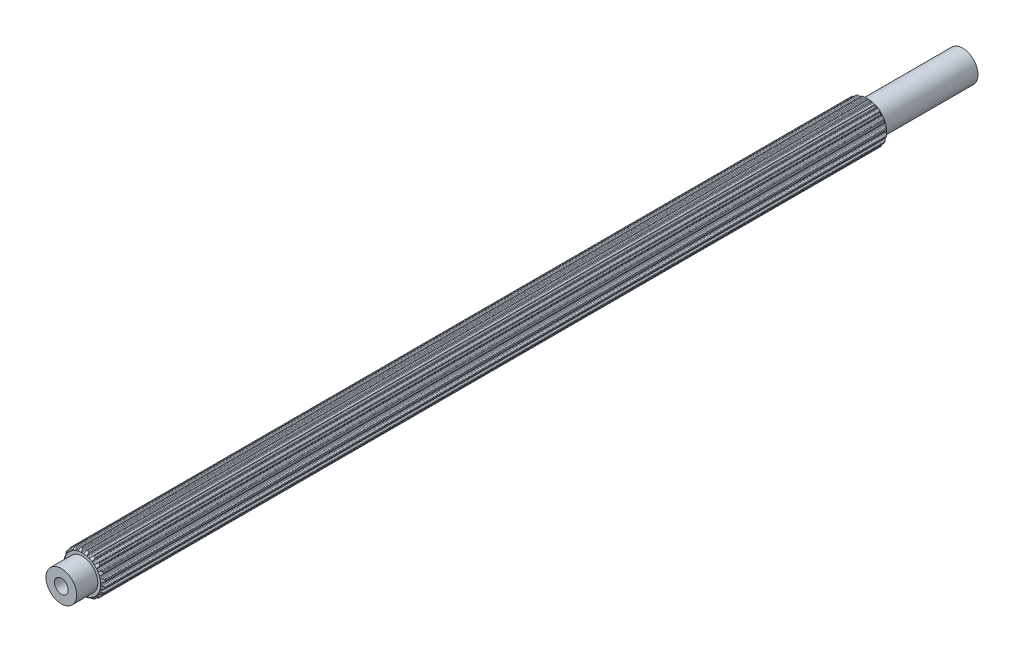
from build123d import *

# Parameters (mm, degrees)
BOSS_EXTRUDE1_DEPTH            = 70.0786
BOSS_EXTRUDE1_DEPTH_BACK       = 58.1406
SKETCH2_R                      = 2.5019
BOSS_EXTRUDE2_DEPTH            = 73.533
CUT_EXTRUDE1_REACH             = 75.533
SKETCH6_R                      = 1.1303
CUT_EXTRUDE1_DIRECTION_2_REACH = 75.533
SKETCH7_R                      = 1.1303
BOSS_EXTRUDE3_DEPTH            = 64.008
BOSS_EXTRUDE3_DEPTH_BACK       = 64.008


with BuildPart() as part:
    # Sketch1 → Boss-Extrude1 (new body, two sides)
    with BuildSketch(Plane.XY) as boss_extrude1_sk:
        with BuildLine():
            Line((-0.106949245, 2.969874934), (0.106949245, 2.969874934))
            ThreePointArc((0.106949245, 2.969874934), (0.196343213, 2.986924176), (0.253739238, 3.057547504))
            Line((0.253739238, 3.057547504), (0.315888147, 3.237526941))
            ThreePointArc((0.315888147, 3.237526941), (0.359032156, 3.298322911), (0.4281449, 3.326269005))
            Line((0.4281449, 3.326269005), (0.620027588, 3.2937547))
            ThreePointArc((0.620027588, 3.2937547), (0.689621142, 3.24802576), (0.718272212, 3.169836791))
            Line((0.718272212, 3.169836791), (0.724389167, 2.979527391))
            ThreePointArc((0.724389167, 2.979527391), (0.750934762, 2.9040661), (0.816027049, 2.857568043))
            Line((0.816027049, 2.857568043), (1.019456602, 2.791469774))
            ThreePointArc((1.019456602, 2.791469774), (1.109743823, 2.780060312), (1.186154496, 2.829490741))
            Line((1.186154496, 2.829490741), (1.300878326, 2.981456288))
            ThreePointArc((1.300878326, 2.981456288), (1.360697704, 3.02594446), (1.435063648, 3.031165762))
            Line((1.435063648, 3.031165762), (1.607507455, 2.940947809))
            ThreePointArc((1.607507455, 2.940947809), (1.659563839, 2.875951412), (1.662650905, 2.792735615))
            Line((1.662650905, 2.792735615), (1.609659636, 2.609850378))
            ThreePointArc((1.609659636, 2.609850378), (1.611587176, 2.529879385), (1.659124931, 2.465542482))
            Line((1.659124931, 2.465542482), (1.832172444, 2.339816104))
            ThreePointArc((1.832172444, 2.339816104), (1.914514976, 2.301064775), (2.002460687, 2.32446371))
            Line((2.002460687, 2.32446371), (2.158529469, 2.433539921))
            ThreePointArc((2.158529469, 2.433539921), (2.229168681, 2.457365482), (2.301508367, 2.439350895))
            Line((2.301508367, 2.439350895), (2.437633293, 2.300260456))
            ThreePointArc((2.437633293, 2.300260456), (2.467056864, 2.222358901), (2.444277744, 2.14226202))
            Line((2.444277744, 2.14226202), (2.337365406, 1.984703026))
            ThreePointArc((2.337365406, 1.984703026), (2.314486209, 1.908050449), (2.339816104, 1.832172444))
            Line((2.339816104, 1.832172444), (2.465542482, 1.659124931))
            ThreePointArc((2.465542482, 1.659124931), (2.531880064, 1.596824985), (2.622752074, 1.591901975))
            Line((2.622752074, 1.591901975), (2.804888709, 1.64741171))
            ThreePointArc((2.804888709, 1.64741171), (2.879433095, 1.648242449), (2.942665411, 1.608755366))
            Line((2.942665411, 1.608755366), (3.0291466, 1.434407582))
            ThreePointArc((3.0291466, 1.434407582), (3.033057175, 1.351226417), (2.986641646, 1.282088892))
            Line((2.986641646, 1.282088892), (2.836273564, 1.165279113))
            ThreePointArc((2.836273564, 1.165279113), (2.790827206, 1.099448241), (2.791469774, 1.019456602))
            Line((2.791469774, 1.019456602), (2.857568043, 0.816027049))
            ThreePointArc((2.857568043, 0.816027049), (2.901407091, 0.736276839), (2.986310214, 0.703513784))
            Line((2.986310214, 0.703513784), (3.1766859, 0.700023363))
            ThreePointArc((3.1766859, 0.700023363), (3.247838536, 0.677777961), (3.295773863, 0.620683653))
            Line((3.295773863, 0.620683653), (3.324145932, 0.4281449))
            ThreePointArc((3.324145932, 0.4281449), (3.302160717, 0.347826477), (3.236652255, 0.29641597))
            Line((3.236652255, 0.29641597), (3.057547504, 0.231789562))
            ThreePointArc((3.057547504, 0.231789562), (2.993982591, 0.183224379), (2.969874934, 0.106949245))
            Line((2.969874934, 0.106949245), (2.969874934, -0.106949245))
            ThreePointArc((2.969874934, -0.106949245), (2.986924176, -0.196343213), (3.057547504, -0.253739238))
            Line((3.057547504, -0.253739238), (3.237526941, -0.315888147))
            ThreePointArc((3.237526941, -0.315888147), (3.298322911, -0.359032156), (3.326269005, -0.4281449))
            Line((3.326269005, -0.4281449), (3.2937547, -0.620027588))
            ThreePointArc((3.2937547, -0.620027588), (3.24802576, -0.689621142), (3.169836791, -0.718272212))
            Line((3.169836791, -0.718272212), (2.979527391, -0.724389167))
            ThreePointArc((2.979527391, -0.724389167), (2.9040661, -0.750934762), (2.857568043, -0.816027049))
            Line((2.857568043, -0.816027049), (2.791469774, -1.019456602))
            ThreePointArc((2.791469774, -1.019456602), (2.780060312, -1.109743823), (2.829490741, -1.186154496))
            Line((2.829490741, -1.186154496), (2.981456288, -1.300878326))
            ThreePointArc((2.981456288, -1.300878326), (3.02594446, -1.360697704), (3.031165762, -1.435063648))
            Line((3.031165762, -1.435063648), (2.940947809, -1.607507455))
            ThreePointArc((2.940947809, -1.607507455), (2.875951412, -1.659563839), (2.792735615, -1.662650905))
            Line((2.792735615, -1.662650905), (2.609850378, -1.609659636))
            ThreePointArc((2.609850378, -1.609659636), (2.529879385, -1.611587176), (2.465542482, -1.659124931))
            Line((2.465542482, -1.659124931), (2.339816104, -1.832172444))
            ThreePointArc((2.339816104, -1.832172444), (2.301064775, -1.914514976), (2.32446371, -2.002460687))
            Line((2.32446371, -2.002460687), (2.433539921, -2.158529469))
            ThreePointArc((2.433539921, -2.158529469), (2.457365482, -2.229168681), (2.439350895, -2.301508367))
            Line((2.439350895, -2.301508367), (2.300260456, -2.437633293))
            ThreePointArc((2.300260456, -2.437633293), (2.222358901, -2.467056864), (2.14226202, -2.444277744))
            Line((2.14226202, -2.444277744), (1.984703026, -2.337365406))
            ThreePointArc((1.984703026, -2.337365406), (1.908050449, -2.314486209), (1.832172444, -2.339816104))
            Line((1.832172444, -2.339816104), (1.659124931, -2.465542482))
            ThreePointArc((1.659124931, -2.465542482), (1.596824985, -2.531880064), (1.591901975, -2.622752074))
            Line((1.591901975, -2.622752074), (1.64741171, -2.804888709))
            ThreePointArc((1.64741171, -2.804888709), (1.648242449, -2.879433095), (1.608755366, -2.942665411))
            Line((1.608755366, -2.942665411), (1.434407582, -3.0291466))
            ThreePointArc((1.434407582, -3.0291466), (1.351226417, -3.033057175), (1.282088892, -2.986641646))
            Line((1.282088892, -2.986641646), (1.165279113, -2.836273564))
            ThreePointArc((1.165279113, -2.836273564), (1.099448241, -2.790827206), (1.019456602, -2.791469774))
            Line((1.019456602, -2.791469774), (0.816027049, -2.857568043))
            ThreePointArc((0.816027049, -2.857568043), (0.736276839, -2.901407091), (0.703513784, -2.986310214))
            Line((0.703513784, -2.986310214), (0.700023363, -3.1766859))
            ThreePointArc((0.700023363, -3.1766859), (0.677777961, -3.247838536), (0.620683653, -3.295773863))
            Line((0.620683653, -3.295773863), (0.4281449, -3.324145932))
            ThreePointArc((0.4281449, -3.324145932), (0.347826477, -3.302160717), (0.29641597, -3.236652255))
            Line((0.29641597, -3.236652255), (0.231789562, -3.057547504))
            ThreePointArc((0.231789562, -3.057547504), (0.183224379, -2.993982591), (0.106949245, -2.969874934))
            Line((0.106949245, -2.969874934), (-0.106949245, -2.969874934))
            ThreePointArc((-0.106949245, -2.969874934), (-0.196343213, -2.986924176), (-0.253739238, -3.057547504))
            Line((-0.253739238, -3.057547504), (-0.315888147, -3.237526941))
            ThreePointArc((-0.315888147, -3.237526941), (-0.359032156, -3.298322911), (-0.4281449, -3.326269005))
            Line((-0.4281449, -3.326269005), (-0.620027588, -3.2937547))
            ThreePointArc((-0.620027588, -3.2937547), (-0.689621142, -3.24802576), (-0.718272212, -3.169836791))
            Line((-0.718272212, -3.169836791), (-0.724389167, -2.979527391))
            ThreePointArc((-0.724389167, -2.979527391), (-0.750934762, -2.9040661), (-0.816027049, -2.857568043))
            Line((-0.816027049, -2.857568043), (-1.019456602, -2.791469774))
            ThreePointArc((-1.019456602, -2.791469774), (-1.109743823, -2.780060312), (-1.186154496, -2.829490741))
            Line((-1.186154496, -2.829490741), (-1.300878326, -2.981456288))
            ThreePointArc((-1.300878326, -2.981456288), (-1.360697704, -3.02594446), (-1.435063648, -3.031165762))
            Line((-1.435063648, -3.031165762), (-1.607507455, -2.940947809))
            ThreePointArc((-1.607507455, -2.940947809), (-1.659563839, -2.875951412), (-1.662650905, -2.792735615))
            Line((-1.662650905, -2.792735615), (-1.609659636, -2.609850378))
            ThreePointArc((-1.609659636, -2.609850378), (-1.611587176, -2.529879385), (-1.659124931, -2.465542482))
            Line((-1.659124931, -2.465542482), (-1.832172444, -2.339816104))
            ThreePointArc((-1.832172444, -2.339816104), (-1.914514976, -2.301064775), (-2.002460687, -2.32446371))
            Line((-2.002460687, -2.32446371), (-2.158529469, -2.433539921))
            ThreePointArc((-2.158529469, -2.433539921), (-2.229168681, -2.457365482), (-2.301508367, -2.439350895))
            Line((-2.301508367, -2.439350895), (-2.437633293, -2.300260456))
            ThreePointArc((-2.437633293, -2.300260456), (-2.467056864, -2.222358901), (-2.444277744, -2.14226202))
            Line((-2.444277744, -2.14226202), (-2.337365406, -1.984703026))
            ThreePointArc((-2.337365406, -1.984703026), (-2.314486209, -1.908050449), (-2.339816104, -1.832172444))
            Line((-2.339816104, -1.832172444), (-2.465542482, -1.659124931))
            ThreePointArc((-2.465542482, -1.659124931), (-2.531880064, -1.596824985), (-2.622752074, -1.591901975))
            Line((-2.622752074, -1.591901975), (-2.804888709, -1.64741171))
            ThreePointArc((-2.804888709, -1.64741171), (-2.879433095, -1.648242449), (-2.942665411, -1.608755366))
            Line((-2.942665411, -1.608755366), (-3.0291466, -1.434407582))
            ThreePointArc((-3.0291466, -1.434407582), (-3.033057175, -1.351226417), (-2.986641646, -1.282088892))
            Line((-2.986641646, -1.282088892), (-2.836273564, -1.165279113))
            ThreePointArc((-2.836273564, -1.165279113), (-2.790827206, -1.099448241), (-2.791469774, -1.019456602))
            Line((-2.791469774, -1.019456602), (-2.857568043, -0.816027049))
            ThreePointArc((-2.857568043, -0.816027049), (-2.901407091, -0.736276839), (-2.986310214, -0.703513784))
            Line((-2.986310214, -0.703513784), (-3.1766859, -0.700023363))
            ThreePointArc((-3.1766859, -0.700023363), (-3.247838536, -0.677777961), (-3.295773863, -0.620683653))
            Line((-3.295773863, -0.620683653), (-3.324145932, -0.4281449))
            ThreePointArc((-3.324145932, -0.4281449), (-3.302160717, -0.347826477), (-3.236652255, -0.29641597))
            Line((-3.236652255, -0.29641597), (-3.057547504, -0.231789562))
            ThreePointArc((-3.057547504, -0.231789562), (-2.993982591, -0.183224379), (-2.969874934, -0.106949245))
            Line((-2.969874934, -0.106949245), (-2.969874934, 0.106949245))
            ThreePointArc((-2.969874934, 0.106949245), (-2.986924176, 0.196343213), (-3.057547504, 0.253739238))
            Line((-3.057547504, 0.253739238), (-3.237526941, 0.315888147))
            ThreePointArc((-3.237526941, 0.315888147), (-3.298322911, 0.359032156), (-3.326269005, 0.4281449))
            Line((-3.326269005, 0.4281449), (-3.2937547, 0.620027588))
            ThreePointArc((-3.2937547, 0.620027588), (-3.24802576, 0.689621142), (-3.169836791, 0.718272212))
            Line((-3.169836791, 0.718272212), (-2.979527391, 0.724389167))
            ThreePointArc((-2.979527391, 0.724389167), (-2.9040661, 0.750934762), (-2.857568043, 0.816027049))
            Line((-2.857568043, 0.816027049), (-2.791469774, 1.019456602))
            ThreePointArc((-2.791469774, 1.019456602), (-2.780060312, 1.109743823), (-2.829490741, 1.186154496))
            Line((-2.829490741, 1.186154496), (-2.981456288, 1.300878326))
            ThreePointArc((-2.981456288, 1.300878326), (-3.02594446, 1.360697704), (-3.031165762, 1.435063648))
            Line((-3.031165762, 1.435063648), (-2.940947809, 1.607507455))
            ThreePointArc((-2.940947809, 1.607507455), (-2.875951412, 1.659563839), (-2.792735615, 1.662650905))
            Line((-2.792735615, 1.662650905), (-2.609850378, 1.609659636))
            ThreePointArc((-2.609850378, 1.609659636), (-2.529879385, 1.611587176), (-2.465542482, 1.659124931))
            Line((-2.465542482, 1.659124931), (-2.339816104, 1.832172444))
            ThreePointArc((-2.339816104, 1.832172444), (-2.301064775, 1.914514976), (-2.32446371, 2.002460687))
            Line((-2.32446371, 2.002460687), (-2.433539921, 2.158529469))
            ThreePointArc((-2.433539921, 2.158529469), (-2.457365482, 2.229168681), (-2.439350895, 2.301508367))
            Line((-2.439350895, 2.301508367), (-2.300260456, 2.437633293))
            ThreePointArc((-2.300260456, 2.437633293), (-2.222358901, 2.467056864), (-2.14226202, 2.444277744))
            Line((-2.14226202, 2.444277744), (-1.984703026, 2.337365406))
            ThreePointArc((-1.984703026, 2.337365406), (-1.908050449, 2.314486209), (-1.832172444, 2.339816104))
            Line((-1.832172444, 2.339816104), (-1.659124931, 2.465542482))
            ThreePointArc((-1.659124931, 2.465542482), (-1.596824985, 2.531880064), (-1.591901975, 2.622752074))
            Line((-1.591901975, 2.622752074), (-1.64741171, 2.804888709))
            ThreePointArc((-1.64741171, 2.804888709), (-1.648242449, 2.879433095), (-1.608755366, 2.942665411))
            Line((-1.608755366, 2.942665411), (-1.434407582, 3.0291466))
            ThreePointArc((-1.434407582, 3.0291466), (-1.351226417, 3.033057175), (-1.282088892, 2.986641646))
            Line((-1.282088892, 2.986641646), (-1.165279113, 2.836273564))
            ThreePointArc((-1.165279113, 2.836273564), (-1.099448241, 2.790827206), (-1.019456602, 2.791469774))
            Line((-1.019456602, 2.791469774), (-0.816027049, 2.857568043))
            ThreePointArc((-0.816027049, 2.857568043), (-0.736276839, 2.901407091), (-0.703513784, 2.986310214))
            Line((-0.703513784, 2.986310214), (-0.700023363, 3.1766859))
            ThreePointArc((-0.700023363, 3.1766859), (-0.677777961, 3.247838536), (-0.620683653, 3.295773863))
            Line((-0.620683653, 3.295773863), (-0.4281449, 3.324145932))
            ThreePointArc((-0.4281449, 3.324145932), (-0.347826477, 3.302160717), (-0.29641597, 3.236652255))
            Line((-0.29641597, 3.236652255), (-0.231789562, 3.057547504))
            ThreePointArc((-0.231789562, 3.057547504), (-0.183224379, 2.993982591), (-0.106949245, 2.969874934))
        make_face()
    extrude(amount=BOSS_EXTRUDE1_DEPTH)
    extrude(boss_extrude1_sk.sketch, amount=-BOSS_EXTRUDE1_DEPTH_BACK)

    # Sketch2 → Boss-Extrude2 (add, symmetric)
    with BuildSketch(Plane.XY):
        Circle(SKETCH2_R)
    extrude(amount=BOSS_EXTRUDE2_DEPTH, both=True)

    # Sketch3 → Cut-Revolve1 (revolve, cut)
    with BuildSketch(Plane(origin=(0, 0, 0), x_dir=(0, 0, -1), z_dir=(1, 0, 0))):
        Polygon((-68.947375505, 4.101099429), (-70.0786, 2.969874934), (-70.0786, 4.101099429), align=None)
        Polygon((58.1406, 54.854469155), (58.1406, 2.969874934), (32.198302889, 28.912172045), align=None)
    revolve(axis=Axis((0, 0, 14.360793934), (0, 0, -1)), mode=Mode.SUBTRACT)

    # Cut-Extrude1: up to this face of the body (flat: up to its plane)
    cut_extrude1_end = Plane(part.part.faces().sort_by_distance((0, 0, 73.533))[0])
    # Sketch6 → Cut-Extrude1 (cut, up to the picked face)
    with BuildSketch(Plane.XY, mode=Mode.PRIVATE) as cut_extrude1_sk1:
        Circle(SKETCH6_R)
    cut_extrude1_tool1 = split(extrude(cut_extrude1_sk1.sketch, amount=CUT_EXTRUDE1_REACH, mode=Mode.PRIVATE), bisect_by=cut_extrude1_end, keep=Keep.BOTH, mode=Mode.PRIVATE)
    add(cut_extrude1_tool1.solids().sort_by_distance((0, 0, 0))[0], mode=Mode.SUBTRACT)

    # Cut-Extrude1 direction 2: up to this face of the body (flat: up to its plane)
    cut_extrude1_direction_2_end = Plane(part.part.faces().sort_by_distance((0, 0, -73.533))[0])
    # Sketch6 → Cut-Extrude1 direction 2 (cut, up to the picked face)
    with BuildSketch(Plane.XY, mode=Mode.PRIVATE) as cut_extrude1_direction_2_sk1:
        Circle(SKETCH6_R)
    cut_extrude1_direction_2_tool1 = split(extrude(cut_extrude1_direction_2_sk1.sketch, amount=-CUT_EXTRUDE1_DIRECTION_2_REACH, mode=Mode.PRIVATE), bisect_by=cut_extrude1_direction_2_end, keep=Keep.BOTH, mode=Mode.PRIVATE)
    add(cut_extrude1_direction_2_tool1.solids().sort_by_distance((0, 0, 0))[0], mode=Mode.SUBTRACT)

    # Sketch7 → Boss-Extrude3 (add, two sides)
    with BuildSketch(Plane.XY) as boss_extrude3_sk:
        Circle(SKETCH7_R)
    extrude(amount=BOSS_EXTRUDE3_DEPTH)
    extrude(boss_extrude3_sk.sketch, amount=-BOSS_EXTRUDE3_DEPTH_BACK)


solid = part.part
